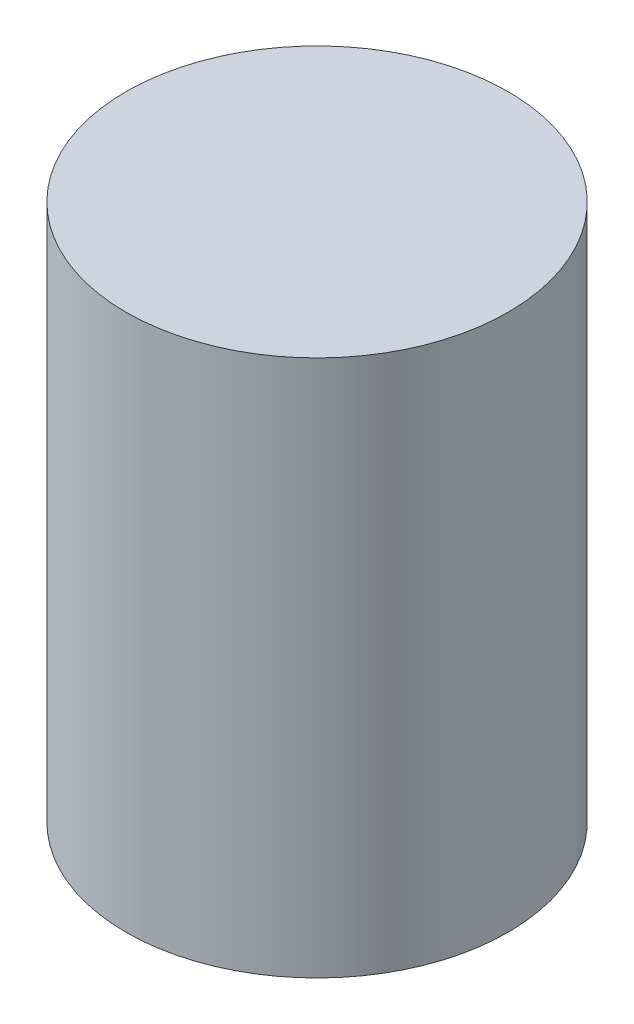
from build123d import *

# Parameters (mm, degrees)
SKETCH1_R           = 1.925
BOSS_EXTRUDE1_DEPTH = 5.4102


with BuildPart() as part:
    # Sketch1 → Boss-Extrude1 (new body)
    with BuildSketch(Plane(origin=(0, 0, 0), x_dir=(1, 0, 0), z_dir=(0, 1, 0))):
        with Locations((0, -45.445)):
            Circle(SKETCH1_R)
    extrude(amount=BOSS_EXTRUDE1_DEPTH)


solid = part.part
